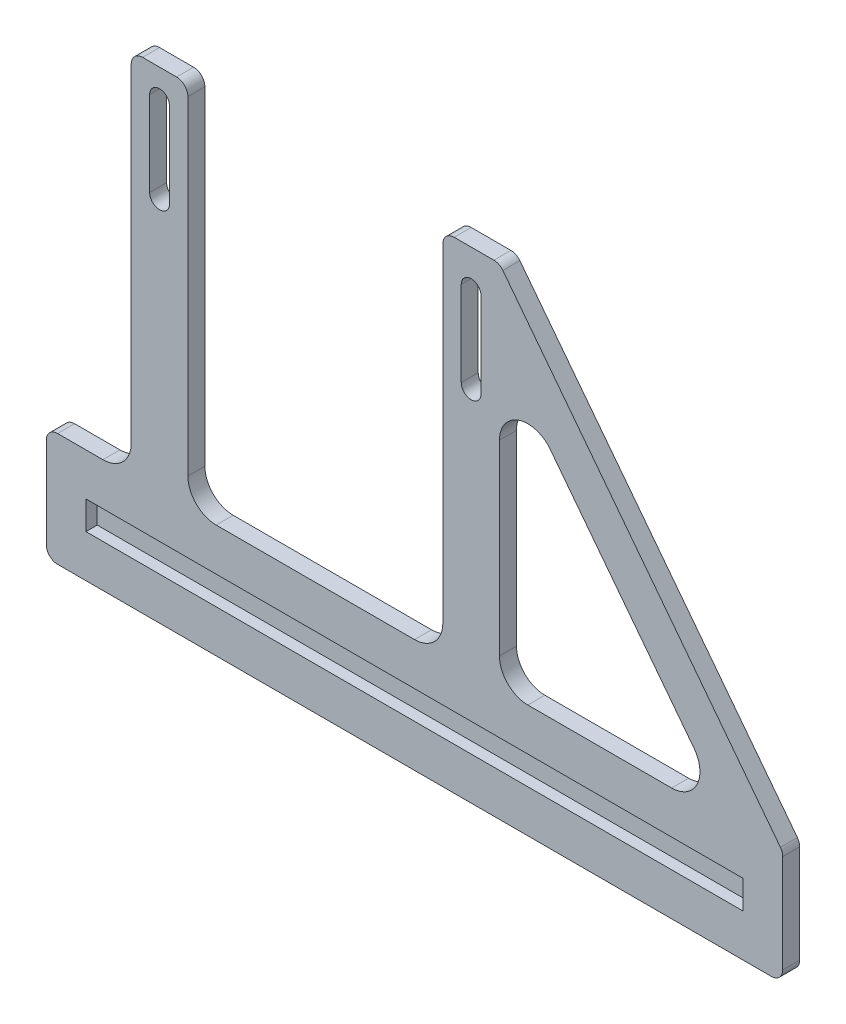
from build123d import *

# Parameters (mm, degrees)
CROQUIS1_W              = 116
CROQUIS1_H              = 5
SALIENTE_EXTRUIR1_DEPTH = 3
CROQUIS1_3_W            = 116
CROQUIS1_3_H            = 5
SALIENTE_EXTRUIR2_DEPTH = 1
REDONDEO1_R             = 5
REDONDEO2_R             = 2


with BuildPart() as part:
    # Croquis1 → Saliente-Extruir1 (new body)
    with BuildSketch(Plane.XY):
        Polygon((-40, 10), (-40, -10), (40, -10), (90, -10), (90, 10), (40, 75), (30, 75), (30, 10), (-15, 10), (-15, 75), (-25, 75), (-25, 10), align=None)
        Polygon((40, 10), (40, 62.6990854), (80.537758, 10), align=None, mode=Mode.SUBTRACT)
        with BuildLine():
            Line((33.25, 68.415525287), (33.25, 53.415525287))
            ThreePointArc((33.25, 53.415525287), (35, 51.665525287), (36.75, 53.415525287))
            Line((36.75, 53.415525287), (36.75, 68.415525287))
            ThreePointArc((36.75, 68.415525287), (35, 70.165525287), (33.25, 68.415525287))
        make_face(mode=Mode.SUBTRACT)
        with Locations((25, 0)):
            Rectangle(CROQUIS1_W, CROQUIS1_H, mode=Mode.SUBTRACT)
        with BuildLine():
            Line((-18.25, 69.952267229), (-18.25, 54.952267229))
            ThreePointArc((-18.25, 54.952267229), (-20, 53.202267229), (-21.75, 54.952267229))
            Line((-21.75, 54.952267229), (-21.75, 69.952267229))
            ThreePointArc((-21.75, 69.952267229), (-20, 71.702267229), (-18.25, 69.952267229))
        make_face(mode=Mode.SUBTRACT)
    extrude(amount=SALIENTE_EXTRUIR1_DEPTH)

    # Croquis1_3 → Saliente-Extruir2 (add)
    with BuildSketch(Plane.XY):
        with Locations((25, 0)):
            Rectangle(CROQUIS1_3_W, CROQUIS1_3_H)
    extrude(amount=SALIENTE_EXTRUIR2_DEPTH)

    # Redondeo1
    redondeo1_edges = [part.edges().sort_by_distance(p)[0] for p in [
        (40, 62.6990854, 1.5),
        (80.537758, 10, 1.5),
        (40, 10, 1.5),
        (-25, 10, 1.5),
        (30, 10, 1.5),
        (-15, 10, 1.5),
    ]]
    fillet(redondeo1_edges, radius=REDONDEO1_R)

    # Redondeo2
    redondeo2_edges = [part.edges().sort_by_distance(p)[0] for p in [
        (30, 75, 1.5),
        (90, 10, 1.5),
        (40, 75, 1.5),
        (90, -10, 1.5),
        (-40, 10, 1.5),
        (-40, -10, 1.5),
        (-25, 75, 1.5),
        (-15, 75, 1.5),
    ]]
    fillet(redondeo2_edges, radius=REDONDEO2_R)


solid = part.part
